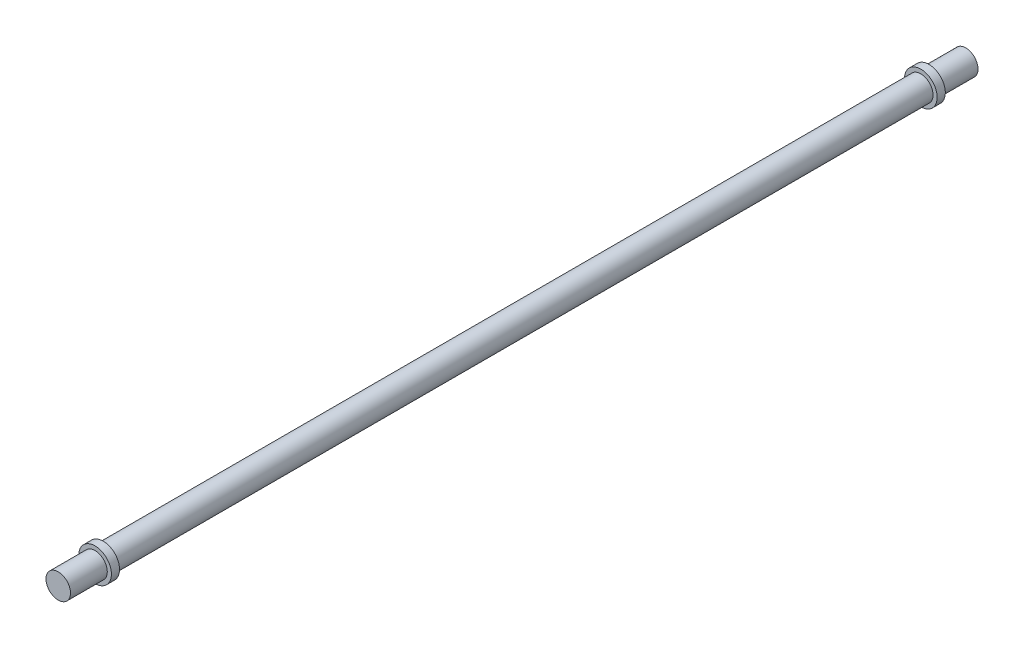
from build123d import *

# Parameters (mm, degrees)
SKETCH1_R           = 15
BOSS_EXTRUDE1_DEPTH = 1000
SKETCH2_R           = 20
BOSS_EXTRUDE2_DEPTH = 10
SKETCH3_R           = 15
BOSS_EXTRUDE3_DEPTH = 45
SKETCH4_R           = 20
BOSS_EXTRUDE4_DEPTH = 10
SKETCH5_R           = 15
BOSS_EXTRUDE5_DEPTH = 45


with BuildPart() as part:
    # Sketch1 → Boss-Extrude1 (new body)
    with BuildSketch(Plane.XY):
        Circle(SKETCH1_R)
    extrude(amount=BOSS_EXTRUDE1_DEPTH)

    # Sketch2 → Boss-Extrude2 (add)
    with BuildSketch(Plane.XY.offset(1000)):
        Circle(SKETCH2_R)
    extrude(amount=BOSS_EXTRUDE2_DEPTH)

    # Sketch3 → Boss-Extrude3 (add)
    with BuildSketch(Plane.XY.offset(1010)):
        Circle(SKETCH3_R)
    extrude(amount=BOSS_EXTRUDE3_DEPTH)

    # Sketch4 → Boss-Extrude4 (add)
    with BuildSketch(Plane(origin=(0, 0, 0), x_dir=(-1, 0, 0), z_dir=(0, 0, -1))):
        Circle(SKETCH4_R)
    extrude(amount=BOSS_EXTRUDE4_DEPTH)

    # Sketch5 → Boss-Extrude5 (add)
    with BuildSketch(Plane(origin=(0, 0, -10), x_dir=(-1, 0, 0), z_dir=(0, 0, -1))):
        Circle(SKETCH5_R)
    extrude(amount=BOSS_EXTRUDE5_DEPTH)


solid = part.part
